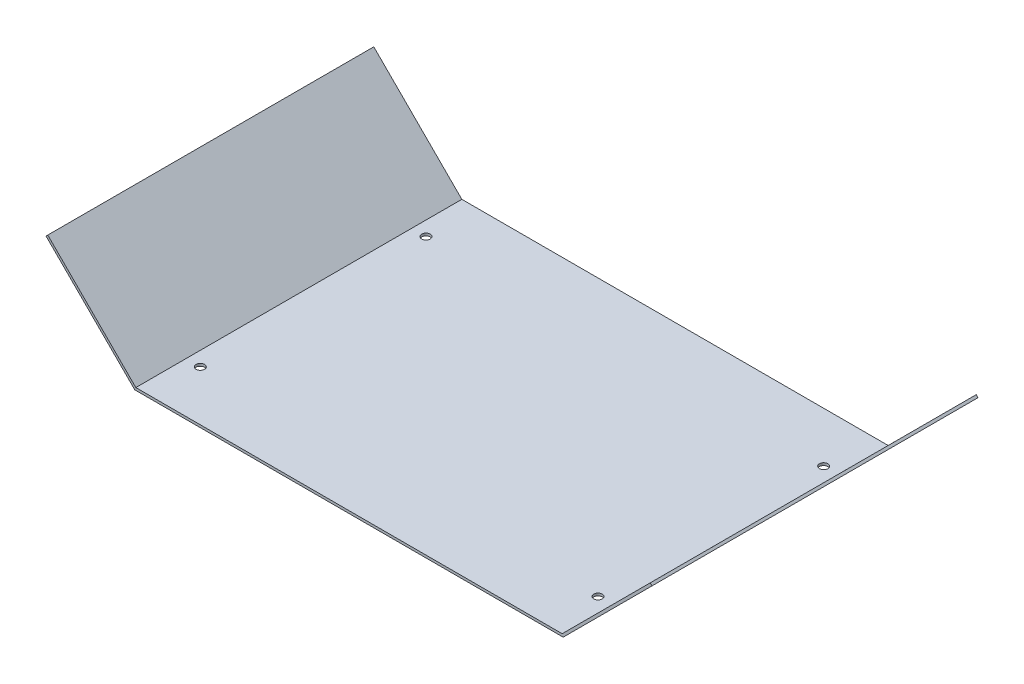
from build123d import *

# Parameters (mm, degrees)
EXTRU_MINCE1_DEPTH = 130
D_GAGEMENT_M32_D   = 3.4


with BuildPart() as part:
    # Esquisse2 → Extru.-Mince1 (new body)
    with BuildSketch(Plane.XY):
        Polygon((-59.170699115, 35.114), (-24.057682042, 0), (145.942317958, 0), (181.056317958, 35.113017073), (181.763414842, 34.405900395), (146.356523321, -1), (-24.471903803, -1), (-59.877815794, 34.406903116), align=None)
    extrude(amount=EXTRU_MINCE1_DEPTH)

    # Dégagement M32 (through all)
    with Locations(Plane(origin=(0, 0, 0), x_dir=(-1, 0, 0), z_dir=(0, 1, 0))):
        with Locations((18.357682042, 20), (-140.242317958, 20), (-140.242317958, 110), (18.357682042, 110)):
            Hole(D_GAGEMENT_M32_D / 2)


solid = part.part
